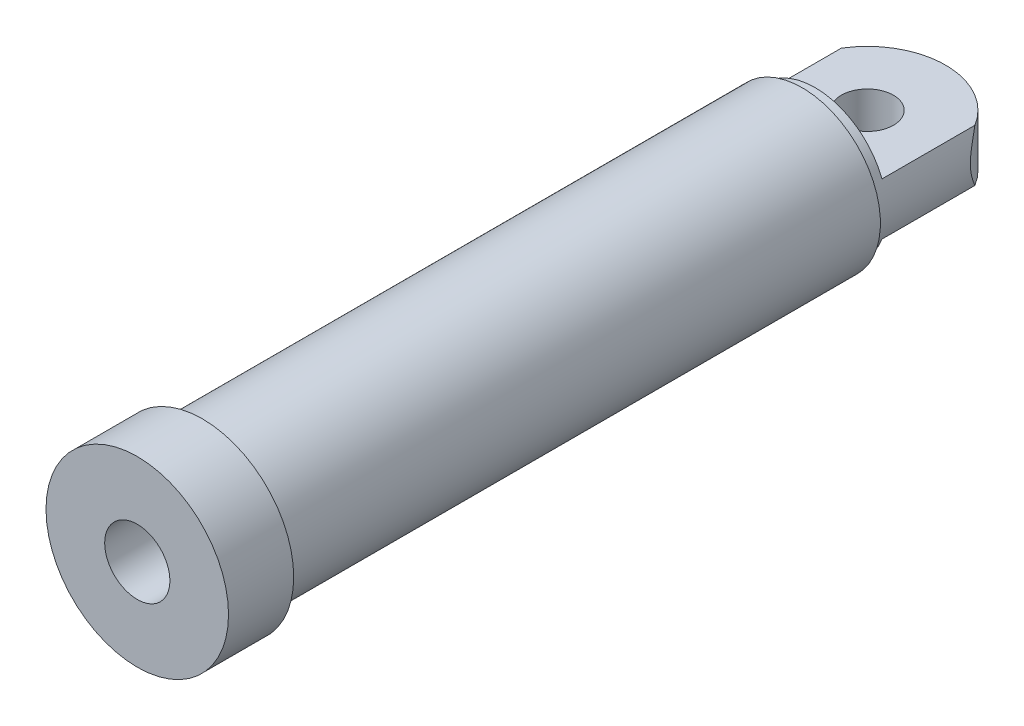
from build123d import *

# Parameters (mm, degrees)
SKETCH2_R               = 20
BOSS_EXTRUDE1_DEPTH     = 20
SKETCH3_R               = 63.245553203
SKETCH3_R_2             = 55
CUT_EXTRUDE1_DEPTH      = 101
CUT_EXTRUDE1_DEPTH_BACK = 10


with BuildPart() as part:
    # Sketch1 → Revolve1 (revolve)
    with BuildSketch(Plane(origin=(0, 0, 0), x_dir=(1, 0, 0), z_dir=(0, 1, 0))):
        Polygon((70, -560), (70, -510), (60, -510), (60, -40), (0, -40), (0, -60), (45, -60), (45, -480), (25, -480), (25, -560), align=None)
    revolve(axis=Axis((0, 0, 0), (0, 0, 1)))

    # Sketch2 → Boss-Extrude1 (add, symmetric)
    with BuildSketch(Plane(origin=(0, 0, 0), x_dir=(1, 0, 0), z_dir=(0, 1, 0))):
        with BuildLine():
            Line((60, -40), (60, 0))
            ThreePointArc((60, 0), (0, 60), (-60, 0))
            Line((-60, 0), (-60, -40))
            Line((-60, -40), (60, -40))
        make_face()
        Circle(SKETCH2_R, mode=Mode.SUBTRACT)
    extrude(amount=BOSS_EXTRUDE1_DEPTH, both=True)

    # Sketch3 → Cut-Extrude1 (cut, two sides)
    with BuildSketch(Plane(origin=(0, 0, 40), x_dir=(-1, 0, 0), z_dir=(0, 0, -1))) as cut_extrude1_sk:
        Circle(SKETCH3_R)
        Circle(SKETCH3_R_2, mode=Mode.SUBTRACT)
    extrude(amount=CUT_EXTRUDE1_DEPTH, mode=Mode.SUBTRACT)
    extrude(cut_extrude1_sk.sketch, amount=-CUT_EXTRUDE1_DEPTH_BACK, mode=Mode.SUBTRACT)


solid = part.part
